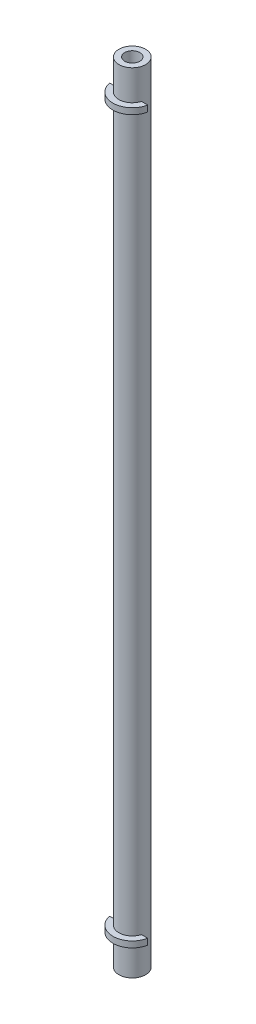
from build123d import *

# Parameters (mm, degrees)
SKETCH1_R           = 2.794
SKETCH1_R_2         = 1.5875
BOSS_EXTRUDE1_DEPTH = 165.1
BOSS_EXTRUDE2_DEPTH = 1.27


with BuildPart() as part:
    # Sketch1 → Boss-Extrude1 (new body)
    with BuildSketch(Plane(origin=(0, 0, 0), x_dir=(1, 0, 0), z_dir=(0, 1, 0))):
        Circle(SKETCH1_R)
        Circle(SKETCH1_R_2, mode=Mode.SUBTRACT)
    extrude(amount=BOSS_EXTRUDE1_DEPTH)

    # Sketch2 → Boss-Extrude2 (add)
    with BuildSketch(Plane(origin=(0, 6.35, 0), x_dir=(-1, 0, 0), z_dir=(0, -1, 0))):
        with BuildLine():
            Line((-3.991923346, -0.762), (-2.688083332, -0.762))
            ThreePointArc((-2.688083332, -0.762), (0, -2.794), (2.688083332, -0.762))
            Line((2.688083332, -0.762), (3.991923346, -0.762))
            ThreePointArc((3.991923346, -0.762), (0, -4.064), (-3.991923346, -0.762))
        make_face()
    boss_extrude2 = extrude(amount=-BOSS_EXTRUDE2_DEPTH)

    # Mirror1: Boss-Extrude2 across plane
    add(boss_extrude2.mirror(Plane(origin=(0, 82.55, 0), x_dir=(0, 0, 1), z_dir=(0, -1, 0))))


solid = part.part
